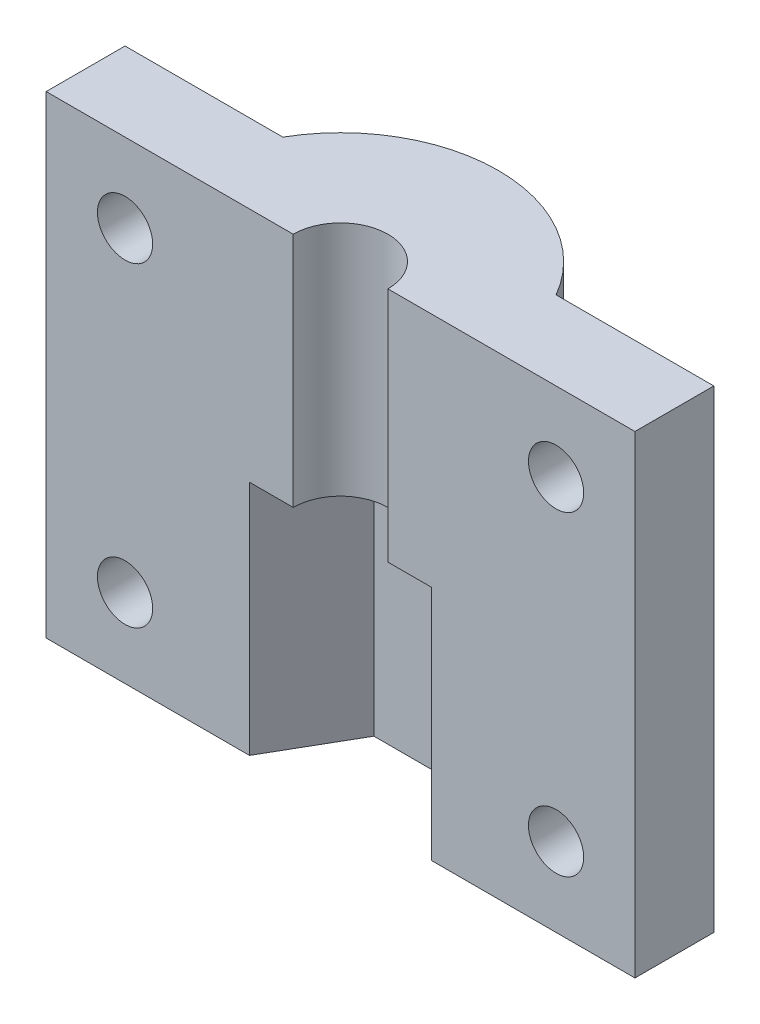
from build123d import *

# Parameters (mm, degrees)
EXTRUDE_1_DEPTH     = 15
EXTRUDE_2_DEPTH     = 15
SKETCH_3_R          = 1.75
CUT_EXTRUDE_1_DEPTH = 6


with BuildPart() as part:
    # Эскиз1 → Бобышка-Вытянуть1 (new body)
    with BuildSketch(Plane(origin=(0, 0, 0), x_dir=(1, 0, 0), z_dir=(0, 1, 0))):
        with BuildLine():
            Line((-5.773502692, 0), (-18.660254038, 0))
            Line((-18.660254038, 0), (-18.660254038, 5))
            Line((-18.660254038, 5), (-8.660254038, 5))
            ThreePointArc((-8.660254038, 5), (0, 10), (8.660254038, 5))
            Line((8.660254038, 5), (18.660254038, 5))
            Line((18.660254038, 5), (18.660254038, 0))
            Line((18.660254038, 0), (5.773502692, 0))
            Line((5.773502692, 0), (2.886751346, 5))
            Line((2.886751346, 5), (-2.886751346, 5))
            Line((-2.886751346, 5), (-5.773502692, 0))
        make_face()
    extrude(amount=EXTRUDE_1_DEPTH)

    # Эскиз2 → Бобышка-Вытянуть2 (add)
    with BuildSketch(Plane(origin=(0, 15, 0), x_dir=(1, 0, 0), z_dir=(0, 1, 0))):
        with BuildLine():
            Line((-18.660254038, 5), (-8.660254038, 5))
            ThreePointArc((-8.660254038, 5), (0, 10), (8.660254038, 5))
            Line((8.660254038, 5), (18.660254038, 5))
            Line((18.660254038, 5), (18.660254038, 0))
            Line((18.660254038, 0), (10, 0))
            Line((10, 0), (3, 0))
            ThreePointArc((3, 0), (0, 3), (-3, 0))
            Line((-3, 0), (-18.660254038, 0))
            Line((-18.660254038, 0), (-18.660254038, 5))
        make_face()
    extrude(amount=EXTRUDE_2_DEPTH)

    # Эскиз3 → Вырез-Вытянуть1 (cut, through all)
    with BuildSketch(Plane(origin=(0, 0, -5), x_dir=(-1, 0, 0), z_dir=(0, 0, -1))):
        with Locations((-13.660254038, 5)):
            Circle(SKETCH_3_R)
        with Locations((-13.660254038, 25)):
            Circle(SKETCH_3_R)
        with Locations((13.660254038, 5)):
            Circle(SKETCH_3_R)
        with Locations((13.660254038, 25)):
            Circle(SKETCH_3_R)
    extrude(amount=-CUT_EXTRUDE_1_DEPTH, mode=Mode.SUBTRACT)


solid = part.part
